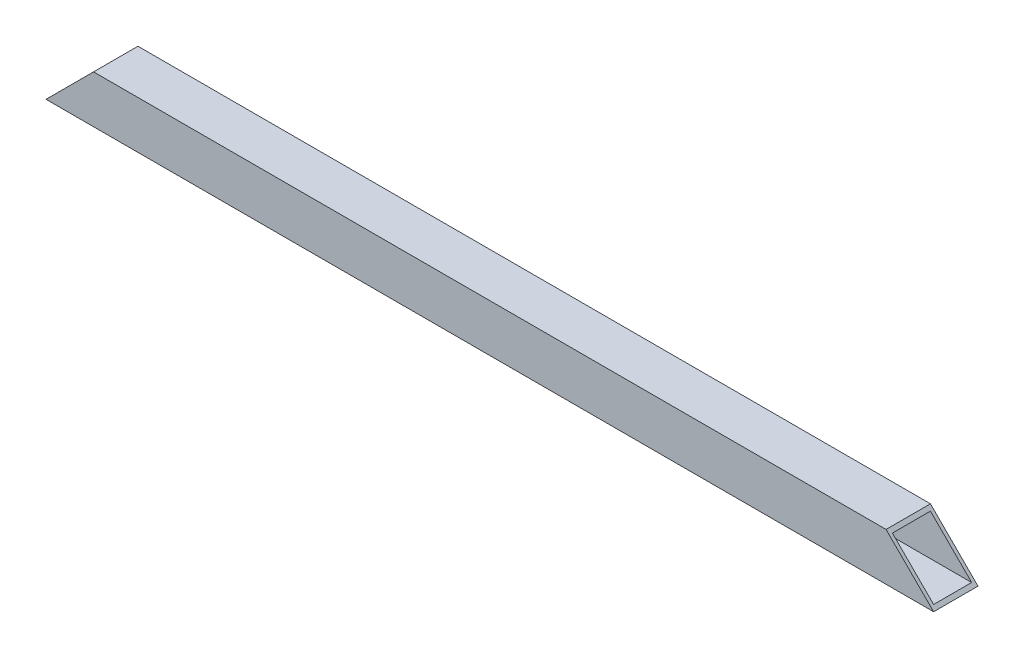
from build123d import *

# Parameters (mm, degrees)
SKETCH_2_W          = 70
SKETCH_2_H          = 75
SKETCH_2_W_2        = 60
SKETCH_2_H_2        = 65
EXTRUDE_1_DEPTH     = 1400
SKETCH_3_OUTSIDE_W  = 1682.75
SKETCH_3_OUTSIDE_H  = 357.75
CUT_EXTRUDE_1_DEPTH = 71


with BuildPart() as part:
    # Эскиз2 → Вытянуть-Тонкостенный1 (new body)
    with BuildSketch(Plane(origin=(0, 0, 0), x_dir=(0, 0, -1), z_dir=(1, 0, 0))):
        Rectangle(SKETCH_2_W, SKETCH_2_H)
        Rectangle(SKETCH_2_W_2, SKETCH_2_H_2, mode=Mode.SUBTRACT)
    extrude(amount=EXTRUDE_1_DEPTH)

    # Эскиз3 outside → Вырез-Вытянуть1 (cut, through all)
    with BuildSketch(Plane(origin=(0, 0, -35), x_dir=(-1, 0, 0), z_dir=(0, 0, -1))):
        with Locations((-700, 0)):
            Rectangle(SKETCH_3_OUTSIDE_W, SKETCH_3_OUTSIDE_H)
        Polygon((-1400, -37.5), (-1325, 37.5), (-75, 37.5), (0, -37.5), align=None, mode=Mode.SUBTRACT)
    extrude(amount=-CUT_EXTRUDE_1_DEPTH, mode=Mode.SUBTRACT)


solid = part.part
